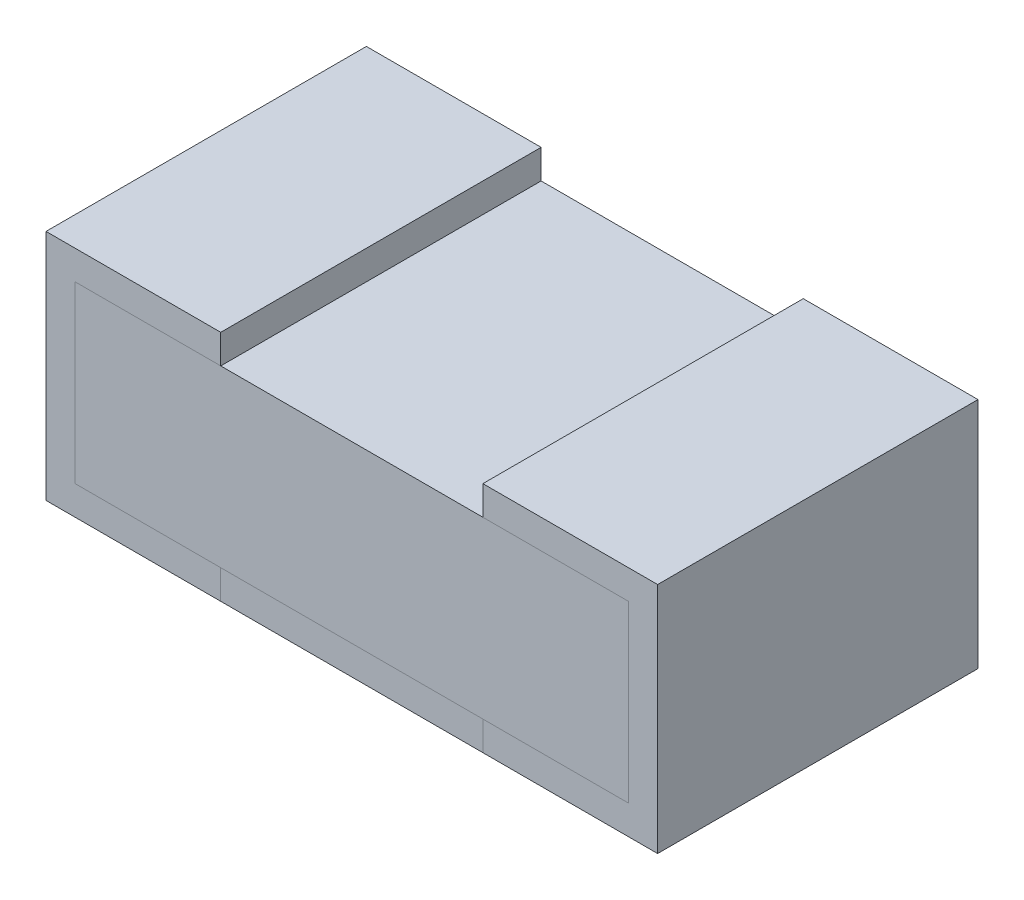
from build123d import *

# Parameters (mm, degrees)
DODANIE_WYCI_GNI_CIE1_DEPTH   = 0.55
DODANIE_WYCI_GNI_CIE1_2_DEPTH = 0.55
SZKIC2_W                      = 0.45
SZKIC2_H                      = 0.05
DODANIE_WYCI_GNI_CIE2_DEPTH   = 0.55
SZKIC3_W                      = 0.95
SZKIC3_H                      = 0.3
DODANIE_WYCI_GNI_CIE3_DEPTH   = 0.55
SKALA1_SCALE                  = 2.5


with BuildPart() as part:
    # Szkic1 → Dodanie-wyciągnięcie1 (new body)
    with BuildSketch(Plane.XY):
        Polygon((0.3, 0.05), (0.05, 0.05), (0.05, 0.35), (0.3, 0.35), (0.3, 0.4), (0, 0.4), (0, 0), (0.3, 0), align=None)
    extrude(amount=DODANIE_WYCI_GNI_CIE1_DEPTH)


with BuildPart() as body_2:
    # Szkic1 → Dodanie-wyci_gni_cie1 2 (new body)
    with BuildSketch(Plane.XY):
        Polygon((0.75, 0.35), (1, 0.35), (1, 0.05), (0.75, 0.05), (0.75, 0), (1.05, 0), (1.05, 0.4), (0.75, 0.4), align=None)
    extrude(amount=DODANIE_WYCI_GNI_CIE1_2_DEPTH)


with BuildPart() as body_3:
    # Szkic2 → Dodanie-wyciągnięcie2 (new body)
    with BuildSketch(Plane.XY.offset(0.55)):
        with Locations((0.525, 0.025)):
            Rectangle(SZKIC2_W, SZKIC2_H)
    extrude(amount=-DODANIE_WYCI_GNI_CIE2_DEPTH)


with BuildPart() as body_4:
    # Szkic3 → Dodanie-wyciągnięcie3 (new body)
    with BuildSketch(Plane.XY.offset(0.55)):
        with Locations((0.525, 0.2)):
            Rectangle(SZKIC3_W, SZKIC3_H)
    extrude(amount=-DODANIE_WYCI_GNI_CIE3_DEPTH)


with BuildPart() as body_2_1:
    # Skala1: scaled about (0, 0, 0)
    add(body_2.part.scale(SKALA1_SCALE))


with BuildPart() as body_4_1:
    # Skala1: scaled about (0, 0, 0)
    add(body_4.part.scale(SKALA1_SCALE))


with BuildPart() as body_3_1:
    # Skala1: scaled about (0, 0, 0)
    add(body_3.part.scale(SKALA1_SCALE))


with BuildPart() as part_1:
    # Skala1: scaled about (0, 0, 0)
    add(part.part.scale(SKALA1_SCALE))


solid = Compound([body_2_1.part, body_4_1.part, body_3_1.part, part_1.part])
